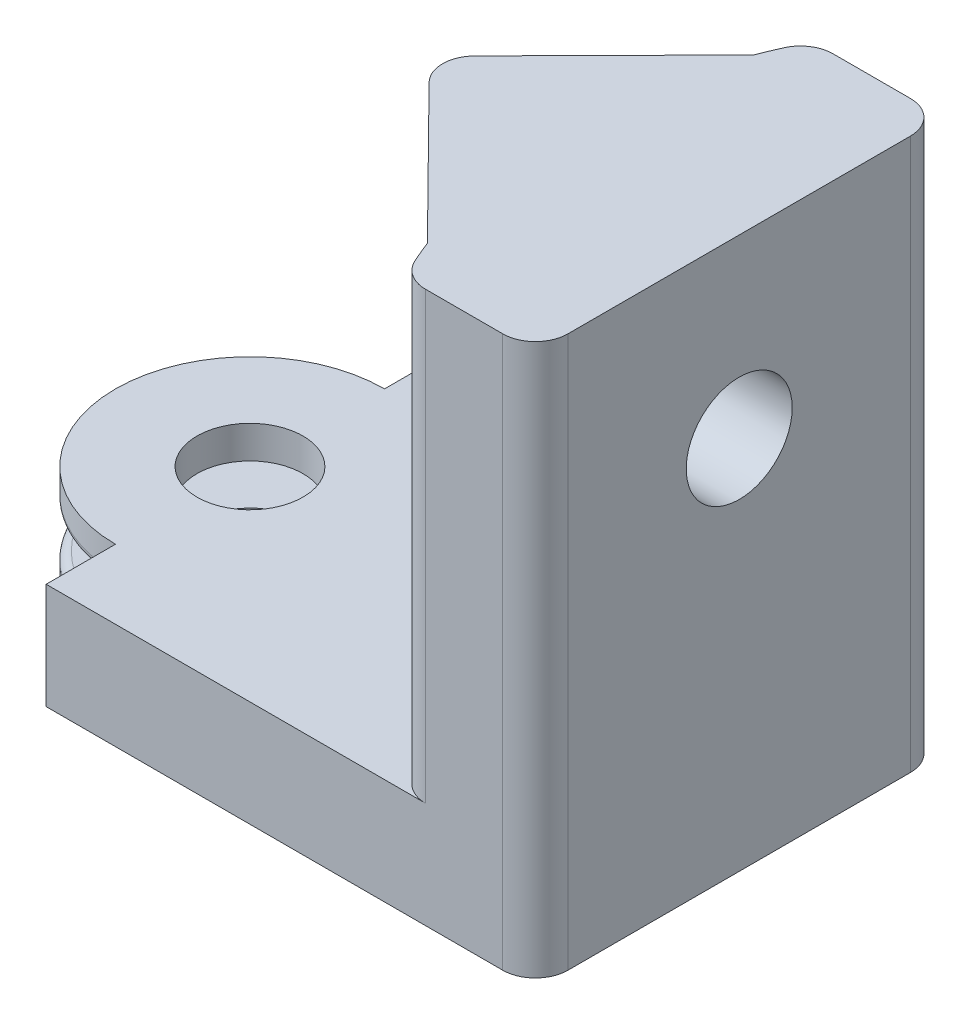
from build123d import *

# Parameters (mm, degrees)
BOSS_EXTRUDE1_DEPTH     = 2
BOSS_EXTRUDE2_START     = 2
BOSS_EXTRUDE2_DEPTH     = 2.5
BOSS_EXTRUDE3_START     = 4.5
SKETCH1_6_R             = 3.25
BOSS_EXTRUDE3_DEPTH     = 2
BOSS_EXTRUDE6_DEPTH     = 33.8
BOSS_EXTRUDE7_DEPTH     = 3.8
FILLET1_R               = 2
FILLET2_R               = 2
FILLET3_R               = 0.5
CUT_EXTRUDE1_REACH      = 54.552
CUT_EXTRUDE1_END_RADIUS = 27.541666667
SKETCH6_R               = 3.25


with BuildPart() as part:
    # Sketch1 → Boss-Extrude1 (new body)
    with BuildSketch(Plane(origin=(0, 0, 0), x_dir=(1, 0, 0), z_dir=(0, 1, 0))):
        with BuildLine():
            ThreePointArc((0, 8.25), (-8.25, 0), (0, -8.25))
            Line((0, -8.25), (0, -3.25))
            ThreePointArc((0, -3.25), (-3.25, 0), (0, 3.25))
            Line((0, 3.25), (0, 8.25))
        make_face()
        with BuildLine():
            Line((0, -3.25), (0, -8.25))
            ThreePointArc((0, -8.25), (5.833630945, -5.833630945), (8.25, 0))
            ThreePointArc((8.25, 0), (5.833630945, 5.833630945), (0, 8.25))
            Line((0, 8.25), (0, 3.25))
            ThreePointArc((0, 3.25), (2.298097039, 2.298097039), (3.25, 0))
            ThreePointArc((3.25, 0), (2.298097039, -2.298097039), (0, -3.25))
        make_face()
        with BuildLine():
            Line((0, -8.25), (0, -9.25))
            ThreePointArc((0, -9.25), (9.25, 0), (0, 9.25))
            Line((0, 9.25), (0, 8.25))
            ThreePointArc((0, 8.25), (5.833630945, 5.833630945), (8.25, 0))
            ThreePointArc((8.25, 0), (5.833630945, -5.833630945), (0, -8.25))
        make_face()
        with BuildLine():
            Line((0, -12.5), (22, -12.5))
            ThreePointArc((22, -12.5), (19, 0), (22, 12.5))
            Line((22, 12.5), (0, 12.5))
            Line((0, 12.5), (0, 9.25))
            ThreePointArc((0, 9.25), (9.25, 0), (0, -9.25))
            Line((0, -9.25), (0, -12.5))
        make_face()
        with BuildLine():
            Line((22, -12.5), (30, -12.5))
            Line((30, -12.5), (30, 12.5))
            Line((30, 12.5), (22, 12.5))
            ThreePointArc((22, 12.5), (19, 0), (22, -12.5))
        make_face()
    extrude(amount=BOSS_EXTRUDE1_DEPTH)

    # Sketch1_4 → Boss-Extrude2 (add)
    with BuildSketch(Plane(origin=(0, 0, 0), x_dir=(1, 0, 0), z_dir=(0, 1, 0)).offset(BOSS_EXTRUDE2_START)):
        with BuildLine():
            Line((30, -12.5), (30, 12.5))
            Line((30, 12.5), (0, 12.5))
            Line((0, 12.5), (0, 9.25))
            ThreePointArc((0, 9.25), (9.25, 0), (0, -9.25))
            Line((0, -9.25), (0, -12.5))
            Line((0, -12.5), (30, -12.5))
        make_face()
    extrude(amount=BOSS_EXTRUDE2_DEPTH)

    # Sketch1_6 → Boss-Extrude3 (add)
    with BuildSketch(Plane(origin=(0, 0, 0), x_dir=(1, 0, 0), z_dir=(0, 1, 0)).offset(BOSS_EXTRUDE3_START)):
        with BuildLine():
            Line((30, -12.5), (30, 12.5))
            Line((30, 12.5), (0, 12.5))
            Line((0, 12.5), (0, 8.25))
            ThreePointArc((0, 8.25), (-8.25, 0), (0, -8.25))
            Line((0, -8.25), (0, -12.5))
            Line((0, -12.5), (30, -12.5))
        make_face()
        with Locations(Location((0, 0, 0), (0, 0, 270))):
            Circle(SKETCH1_6_R, mode=Mode.SUBTRACT)
    extrude(amount=BOSS_EXTRUDE3_DEPTH)

    # Sketch1_8 → Boss-Extrude6 (add)
    with BuildSketch(Plane(origin=(0, 0, 0), x_dir=(1, 0, 0), z_dir=(0, 1, 0))):
        with BuildLine():
            Line((22, -12.5), (30, -12.5))
            Line((30, -12.5), (30, 12.5))
            Line((30, 12.5), (22, 12.5))
            ThreePointArc((22, 12.5), (19, 0), (22, -12.5))
        make_face()
    extrude(amount=BOSS_EXTRUDE6_DEPTH)

    # Sketch3 → Boss-Extrude7 (add)
    with BuildSketch(Plane(origin=(0, 33.8, 0), x_dir=(1, 0, 0), z_dir=(0, 1, 0))):
        with BuildLine():
            Line((11, 0), (19, 0))
            ThreePointArc((19, 0), (19.473969858, 5.087552676), (20.879566153, 10))
            Line((20.879566153, 10), (11, 0))
        make_face()
        with BuildLine():
            ThreePointArc((20.879566153, -10), (19.473969858, -5.087552676), (19, 0))
            Line((19, 0), (11, 0))
            Line((11, 0), (20.879566153, -10))
        make_face()
        with BuildLine():
            ThreePointArc((20.879566153, 10), (19.473969858, 5.087552676), (19, 0))
            ThreePointArc((19, 0), (19.473969858, -5.087552676), (20.879566153, -10))
            ThreePointArc((20.879566153, -10), (21.408679185, -11.263939941), (22, -12.5))
            Line((22, -12.5), (30, -12.5))
            Line((30, -12.5), (30, 12.5))
            Line((30, 12.5), (22, 12.5))
            ThreePointArc((22, 12.5), (21.408679185, 11.263939941), (20.879566153, 10))
        make_face()
    extrude(amount=-BOSS_EXTRUDE7_DEPTH)

    # Fillet1
    fillet1_edges = [part.edges().sort_by_distance(p)[0] for p in [
        (11, 31.9, 0),
    ]]
    fillet(fillet1_edges, radius=FILLET1_R)

    # Fillet2
    fillet2_edges = [part.edges().sort_by_distance(p)[0] for p in [
        (30, 16.9, -12.5),
        (30, 16.9, 12.5),
        (22, 20.15, -12.5),
        (22, 20.15, 12.5),
    ]]
    fillet(fillet2_edges, radius=FILLET2_R)

    # Fillet3
    fillet3_edges = [part.edges().sort_by_distance(p)[0] for p in [
        (0, 2, 8.75),
        (0, 3.25, -9.25),
        (0, 3.25, 9.25),
        (0, 2, -8.75),
        (0, 4.5, -8.75),
        (-8.25, 4.5, 0),
        (0, 4.5, 8.75),
        (-8.25, 2, 0),
    ]]
    fillet(fillet3_edges, radius=FILLET3_R)

    # Cut-Extrude1: up to this cylinder (the profile starts inside it)
    cut_extrude1_end = Plane(origin=(46.541666667, 23, 0), z_dir=(0, -1, 0)) * Cylinder(CUT_EXTRUDE1_END_RADIUS, 165.187333333, mode=Mode.PRIVATE)
    # Sketch6 → Cut-Extrude1 (cut, up to the surface)
    with BuildSketch(Plane(origin=(30, 0, 0), x_dir=(0, 0, -1), z_dir=(1, 0, 0)), mode=Mode.PRIVATE) as cut_extrude1_sk1:
        with Locations((0, 23)):
            Circle(SKETCH6_R)
    cut_extrude1_tool1 = extrude(cut_extrude1_sk1.sketch, amount=-CUT_EXTRUDE1_REACH, mode=Mode.PRIVATE) & cut_extrude1_end
    add(cut_extrude1_tool1.solids().sort_by_distance((30, 23, 0))[0], mode=Mode.SUBTRACT)


solid = part.part
